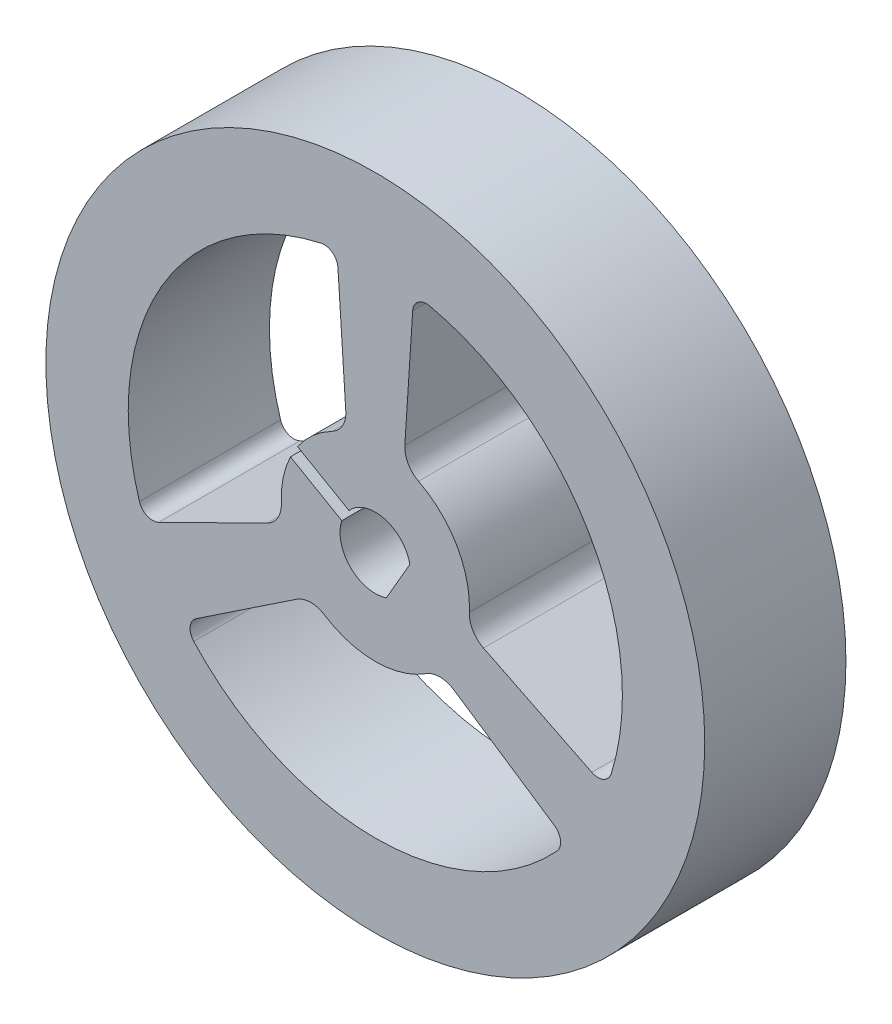
from build123d import *

# Parameters (mm, degrees)
SKETCH_1_R      = 14
EXTRUDE_1_DEPTH = 6


with BuildPart() as part:
    # 草图1 → 凸台-拉伸1 (new body)
    with BuildSketch(Plane.XY):
        Circle(SKETCH_1_R)
        with BuildLine():
            Line((4.596960215, -1.205253518), (9.199687971, -3.477076493))
            ThreePointArc((9.199687971, -3.477076493), (9.69373922, -3.490261664), (10.024736471, -3.123244898))
            ThreePointArc((10.024736471, -3.123244898), (9.09326674, 5.25), (2.307558811, 10.243298899))
            ThreePointArc((2.307558811, 10.243298899), (1.824214343, 10.140155255), (1.588607412, 9.705701736))
            Line((1.588607412, 9.705701736), (1.254699943, 4.583711086))
            ThreePointArc((1.254699943, 4.583711086), (1.392222532, 3.981727051), (1.836894199, 3.553282947))
            ThreePointArc((1.836894199, 3.553282947), (3.464101615, 2), (3.995680398, -0.185844433))
            ThreePointArc((3.995680398, -0.185844433), (4.144388043, -0.785163445), (4.596960215, -1.205253518))
        make_face(mode=Mode.SUBTRACT)
        with BuildLine():
            Line((-1.254699943, 4.583711086), (-1.588607412, 9.705701736))
            ThreePointArc((-1.588607412, 9.705701736), (-1.824214343, 10.140155255), (-2.307558811, 10.243298899))
            ThreePointArc((-2.307558811, 10.243298899), (-9.09326674, 5.25), (-10.024736471, -3.123244898))
            ThreePointArc((-10.024736471, -3.123244898), (-9.69373922, -3.490261664), (-9.199687971, -3.477076493))
            Line((-9.199687971, -3.477076493), (-4.596960215, -1.205253518))
            ThreePointArc((-4.596960215, -1.205253518), (-4.144388043, -0.785163445), (-3.995680398, -0.185844433))
            ThreePointArc((-3.995680398, -0.185844433), (-3.919805533, 0.79694704), (-3.605891638, 1.731342108))
            Line((-3.605891638, 1.731342108), (-1.423938852, 0.471591079))
            ThreePointArc((-1.423938852, 0.471591079), (-1.061904855, -1.059414026), (0.468245837, -1.425042398))
            Line((0.468245837, -1.425042398), (1.468245837, 0.307008409))
            ThreePointArc((1.468245837, 0.307008409), (0.386527032, 1.449343594), (-1.120379281, 0.99737168))
            Line((-1.120379281, 0.99737168), (-3.302332067, 2.257122708))
            ThreePointArc((-3.302332067, 2.257122708), (-2.650079149, 2.996177649), (-1.836894199, 3.553282947))
            ThreePointArc((-1.836894199, 3.553282947), (-1.392222532, 3.981727051), (-1.254699943, 4.583711086))
        make_face(mode=Mode.SUBTRACT)
        with BuildLine():
            Line((3.342260273, -3.378457568), (7.611080559, -6.228625243))
            ThreePointArc((7.611080559, -6.228625243), (7.869524877, -6.649893591), (7.717177659, -7.120054001))
            ThreePointArc((7.717177659, -7.120054001), (0, -10.5), (-7.717177659, -7.120054001))
            ThreePointArc((-7.717177659, -7.120054001), (-7.869524877, -6.649893591), (-7.611080559, -6.228625243))
            Line((-7.611080559, -6.228625243), (-3.342260273, -3.378457568))
            ThreePointArc((-3.342260273, -3.378457568), (-2.752165511, -3.196563606), (-2.1587862, -3.367438514))
            ThreePointArc((-2.1587862, -3.367438514), (0, -4), (2.1587862, -3.367438514))
            ThreePointArc((2.1587862, -3.367438514), (2.752165511, -3.196563606), (3.342260273, -3.378457568))
        make_face(mode=Mode.SUBTRACT)
    extrude(amount=EXTRUDE_1_DEPTH)


solid = part.part
